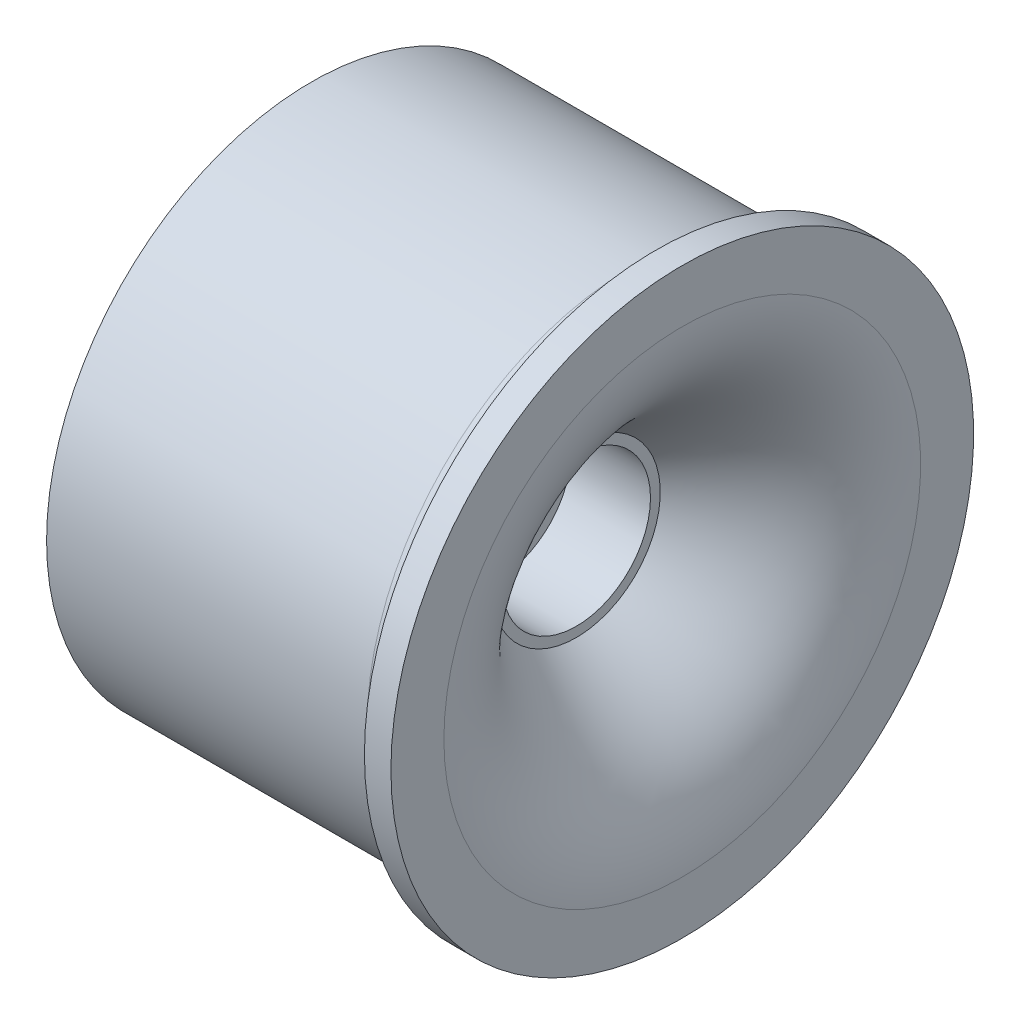
from build123d import *

# Parameters (mm, degrees)
SKETCH2_R           = 5.5
SKETCH2_R_2         = 1
BOSS_EXTRUDE1_DEPTH = 10
SKETCH3_R           = 2.8
CUT_EXTRUDE1_DEPTH  = 3
SKETCH4_R           = 1.42
CUT_EXTRUDE2_DEPTH  = 7
SKETCH5_R           = 22.131734032
SKETCH5_R_2         = 10
CUT_EXTRUDE3_DEPTH  = 10


with BuildPart() as part:
    # Sketch1 → Revolve1 (revolve)
    with BuildSketch(Plane.XY, mode=Mode.PRIVATE) as revolve1_sk:
        with BuildLine():
            Line((-7, 9), (5, 9))
            add(Edge.make_bspline(
                [(5, 9), (5, 8.856466181), (4.980630385, 8.552638111), (4.879856885, 8.085906437), (4.637540593, 7.528306389), (3.996049584, 6.69016035), (2.86097235, 5.618747783), (1.478465211, 4.503997435), (0.514957064, 3.794701588), (0.068439653, 3.476275963), (0, 3.427716912)],
                knots=[0, 0, 0, 0, 0.0625, 0.125, 0.25, 0.375, 0.5, 0.625, 0.75, 0.773497894, 0.773497894, 0.773497894, 0.773497894], degree=3))
            Line((0, 3.427716912), (0, 1))
            add(Edge.make_bspline(
                [(7, 9), (7, 7.437991686), (5.451200792, 4.581787455), (0.00160793, 1.001387392), (0, 1)],
                knots=[0, 0, 0, 0, 0.405901642, 1, 1, 1, 1], degree=3))
            Line((7, 9), (7, 11))
            Line((7, 11), (6, 11))
            Line((6, 11), (6, 10.9))
            ThreePointArc((6, 10.9), (5.736396103, 10.263603897), (5.1, 10))
            Line((5.1, 10), (-5.1, 10))
            ThreePointArc((-5.1, 10), (-5.736396103, 10.263603897), (-6, 10.9))
            Line((-6, 10.9), (-6, 11))
            Line((-6, 11), (-7, 11))
            Line((-7, 11), (-7, 9))
        make_face()
    revolve(revolve1_sk.sketch.rotate(Axis((0, 0, 0), (1, 0, 0)), 90), axis=Axis((0, 0, 0), (1, 0, 0)))

    # Sketch2 → Boss-Extrude1 (add)
    with BuildSketch(Plane.ZY.offset(7)):
        Circle(SKETCH2_R)
        Circle(SKETCH2_R_2, mode=Mode.SUBTRACT)
    extrude(amount=-BOSS_EXTRUDE1_DEPTH)

    # Sketch3 → Cut-Extrude1 (cut)
    with BuildSketch(Plane(origin=(3, 0, 0), x_dir=(0, 0, -1), z_dir=(1, 0, 0))):
        Circle(SKETCH3_R)
    extrude(amount=-CUT_EXTRUDE1_DEPTH, mode=Mode.SUBTRACT)

    # Sketch4 → Cut-Extrude2 (cut)
    with BuildSketch(Plane.ZY.offset(7)):
        Circle(SKETCH4_R)
    extrude(amount=-CUT_EXTRUDE2_DEPTH, mode=Mode.SUBTRACT)

    # Sketch5 → Cut-Extrude3 (cut)
    with BuildSketch(Plane(origin=(0, 0, 0), x_dir=(0, 0, -1), z_dir=(1, 0, 0))):
        Circle(SKETCH5_R)
        with Locations(Location((0, 0, 0), (0, 0, 180))):
            Circle(SKETCH5_R_2, mode=Mode.SUBTRACT)
    extrude(amount=-CUT_EXTRUDE3_DEPTH, mode=Mode.SUBTRACT)


solid = part.part
